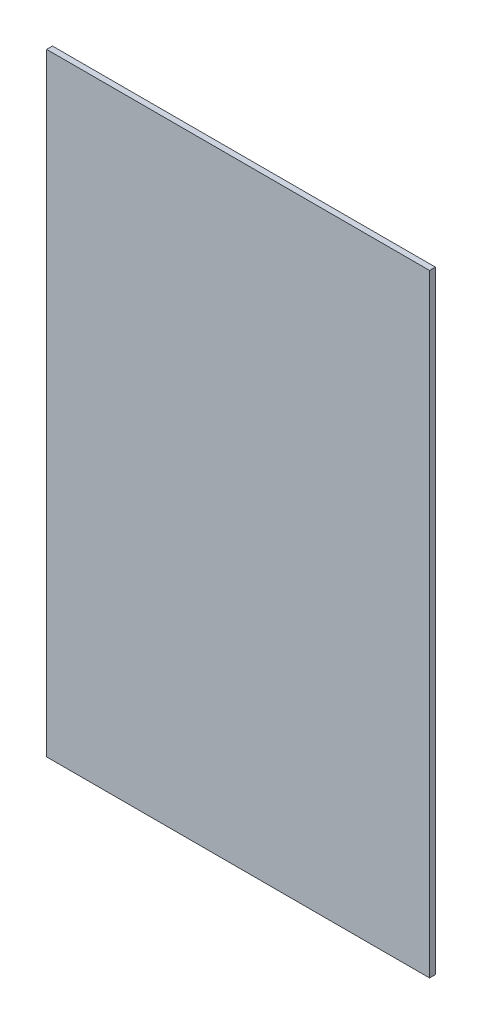
from build123d import *

# Parameters (mm, degrees)
SKETCH1_W           = 50
SKETCH1_H           = 80
BOSS_EXTRUDE1_DEPTH = 0.76


with BuildPart() as part:
    # Sketch1 → Boss-Extrude1 (new body)
    with BuildSketch(Plane.XY):
        with Locations((25, 40)):
            Rectangle(SKETCH1_W, SKETCH1_H)
    extrude(amount=BOSS_EXTRUDE1_DEPTH)


solid = part.part
